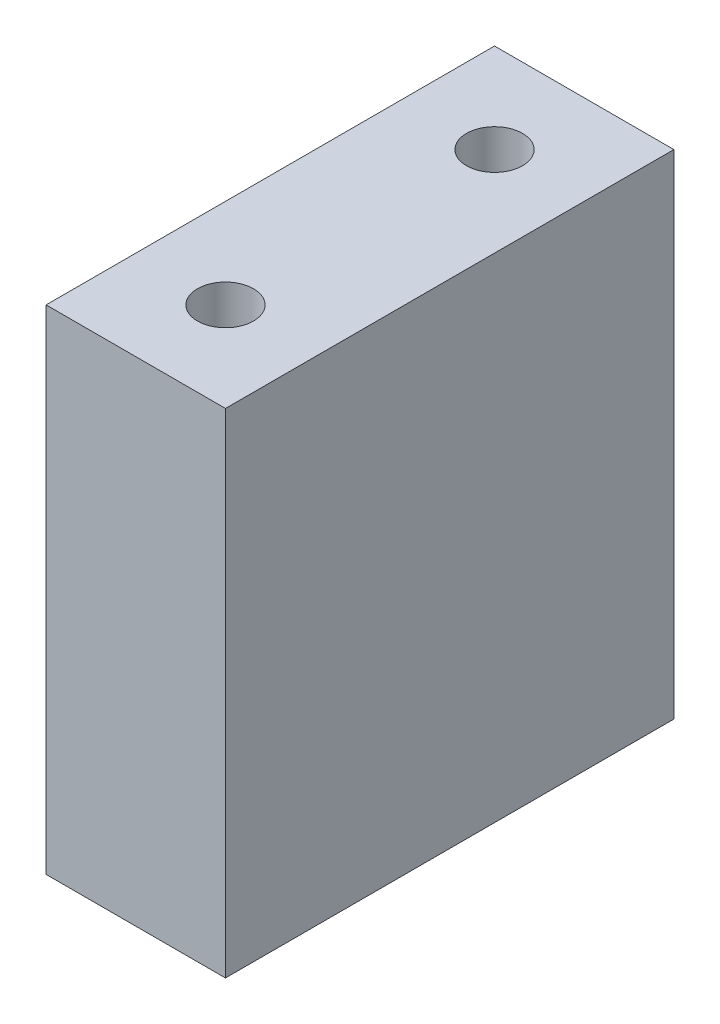
from build123d import *

# Parameters (mm, degrees)
SKETCH1_W                 = 20
SKETCH1_H                 = 22
BOSS_EXTRUDE1_DEPTH       = 4
M3X0_5_TAPPED_HOLE1_D     = 2.5
M3X0_5_TAPPED_HOLE1_DEPTH = 7.5
M3X0_5_TAPPED_HOLE1_TIP   = 0.751075774
M3X0_5_TAPPED_HOLE2_D     = 2.5
M3X0_5_TAPPED_HOLE2_DEPTH = 7.5
M3X0_5_TAPPED_HOLE2_TIP   = 0.751075774


with BuildPart() as part:
    # Sketch1 → Boss-Extrude1 (new body, symmetric)
    with BuildSketch(Plane(origin=(0, 0, 0), x_dir=(0, 0, -1), z_dir=(1, 0, 0))):
        Rectangle(SKETCH1_W, SKETCH1_H)
    extrude(amount=BOSS_EXTRUDE1_DEPTH, both=True)

    # M3x0.5 Tapped Hole1
    with Locations(Plane(origin=(0, 11, 0), x_dir=(1, 0, 0), z_dir=(0, 1, 0))):
        with Locations((0, 6), (0, -6)):
            Hole(M3X0_5_TAPPED_HOLE1_D / 2, depth=M3X0_5_TAPPED_HOLE1_DEPTH)
            with Locations((0, 0, -(M3X0_5_TAPPED_HOLE1_DEPTH + M3X0_5_TAPPED_HOLE1_TIP / 2))):  # 118° drill point
                Cone(0, M3X0_5_TAPPED_HOLE1_D / 2, M3X0_5_TAPPED_HOLE1_TIP, mode=Mode.SUBTRACT)

    # M3x0.5 Tapped Hole2
    with Locations(Plane(origin=(0, -11, 0), x_dir=(-1, 0, 0), z_dir=(0, -1, 0))):
        with Locations((0, -6), (0, 6)):
            Hole(M3X0_5_TAPPED_HOLE2_D / 2, depth=M3X0_5_TAPPED_HOLE2_DEPTH)
            with Locations((0, 0, -(M3X0_5_TAPPED_HOLE2_DEPTH + M3X0_5_TAPPED_HOLE2_TIP / 2))):  # 118° drill point
                Cone(0, M3X0_5_TAPPED_HOLE2_D / 2, M3X0_5_TAPPED_HOLE2_TIP, mode=Mode.SUBTRACT)


solid = part.part
